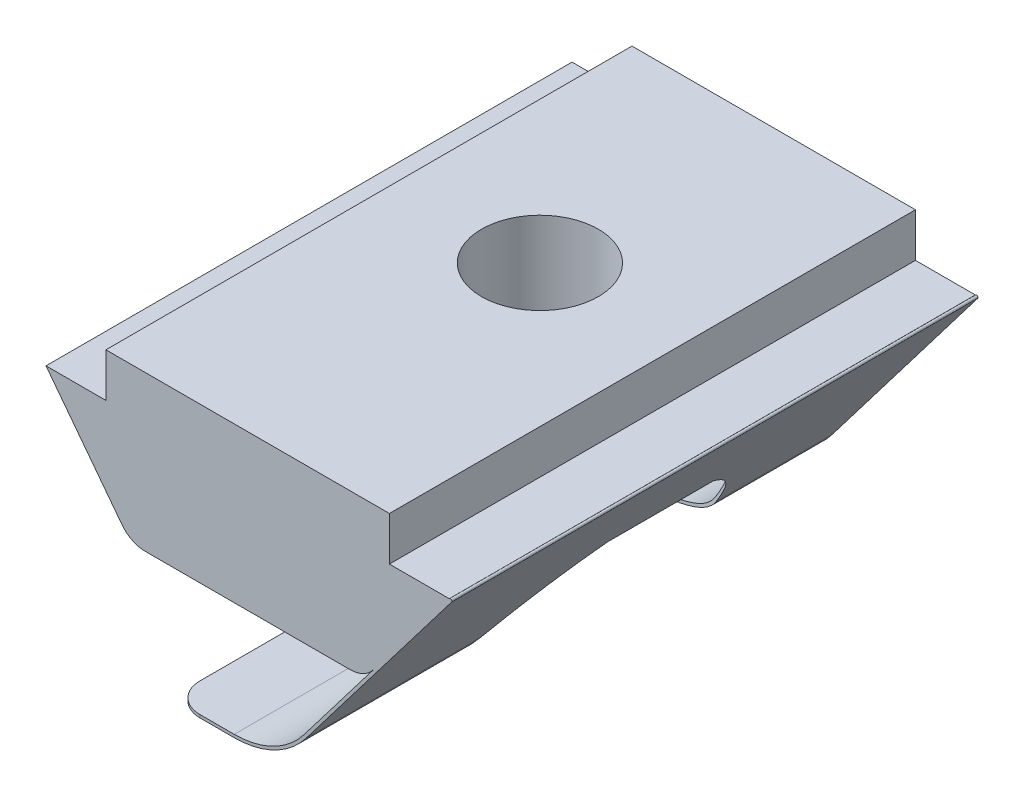
from build123d import *

# Parameters (mm, degrees)
EXTRUDE_1_DEPTH      = 10
EXTRUDE_1_DEPTH_BACK = 8
SKETCH_2_R           = 2
CUT_EXTRUDE_1_DEPTH  = 6.3
EXTRUDE_2_DEPTH      = 18
CUT_EXTRUDE_2_DEPTH  = 4
SKETCH_5_W           = 0.05
SKETCH_5_H           = 18
CUT_EXTRUDE_3_DEPTH  = 1
FILLET_1_R           = 1


with BuildPart() as part:
    # Эскиз1 → Бобышка-Вытянуть1 (new body, two sides)
    with BuildSketch(Plane.XY) as extrude_1_sk:
        with BuildLine():
            Line((3.505219116, 0), (-3.505219116, 0))
            ThreePointArc((-3.505219116, 0), (-3.948686522, 0.1037095), (-4.300170362, 0.393326681))
            Line((-4.300170362, 0.393326681), (-6.9, 3.8))
            Line((-6.9, 3.8), (-4.85, 3.8))
            Line((-4.85, 3.8), (-4.85, 5.3))
            Line((-4.85, 5.3), (4.85, 5.3))
            Line((4.85, 5.3), (4.85, 3.8))
            Line((4.85, 3.8), (6.9, 3.8))
            Line((6.9, 3.8), (4.300170362, 0.393326681))
            ThreePointArc((4.300170362, 0.393326681), (3.948686522, 0.1037095), (3.505219116, 0))
        make_face()
    extrude(amount=EXTRUDE_1_DEPTH)
    extrude(extrude_1_sk.sketch, amount=-EXTRUDE_1_DEPTH_BACK)

    # Эскиз2 → Вырез-Вытянуть1 (cut, through all)
    with BuildSketch(Plane(origin=(0, 5.3, 0), x_dir=(1, 0, 0), z_dir=(0, 1, 0))):
        with Locations(Location((0, 0, 0), (0, 0, 270))):  # turned: the seam where the file's is
            Circle(SKETCH_2_R)
    extrude(amount=-CUT_EXTRUDE_1_DEPTH, mode=Mode.SUBTRACT)

    # Эскиз3 → Бобышка-Вытянуть2 (add)
    with BuildSketch(Plane.XY.offset(10)):
        with BuildLine():
            Line((6.9, 3.8), (1.924195295, -2.720019958))
            ThreePointArc((1.924195295, -2.720019958), (0.869743776, -3.588871499), (-0.460658443, -3.9))
            Line((-0.460658443, -3.9), (-2.630413016, -3.9))
            ThreePointArc((-2.630413016, -3.9), (-2.680413016, -3.95), (-2.630413016, -4))
            Line((-2.630413016, -4), (-0.460658443, -4))
            ThreePointArc((-0.460658443, -4), (0.914090516, -3.678500549), (2.00369042, -2.78068729))
            Line((2.00369042, -2.78068729), (6.979495125, 3.739332668))
            ThreePointArc((6.979495125, 3.739332668), (6.970081228, 3.809413896), (6.9, 3.8))
        make_face()
    extrude(amount=-EXTRUDE_2_DEPTH)

    # Эскиз4 → Вырез-Вытянуть2 (cut)
    with BuildSketch(Plane.XZ.offset(4)):
        with BuildLine():
            Line((0, 4.5), (-4.5, 4.5))
            Line((-4.5, 4.5), (-4.5, 0))
            Line((-4.5, 0), (-4.5, -4.5))
            Line((-4.5, -4.5), (0, -4.5))
            ThreePointArc((0, -4.5), (4.5, 0), (0, 4.5))
        make_face()
    extrude(amount=-CUT_EXTRUDE_2_DEPTH, mode=Mode.SUBTRACT)

    # Эскиз5 → Вырез-Вытянуть3 (cut)
    with BuildSketch(Plane.XZ.offset(4)):
        with Locations((-2.655413016, 1)):
            Rectangle(SKETCH_5_W, SKETCH_5_H)
    extrude(amount=-CUT_EXTRUDE_3_DEPTH, mode=Mode.SUBTRACT)

    # Скругление1
    fillet_1_edges = [part.edges().sort_by_distance(p)[0] for p in [
        (-2.630413016, -3.95, 4.5),
        (-2.630413016, -3.95, -4.5),
        (-2.630413016, -3.95, 10),
        (-2.630413016, -3.95, -8),
    ]]
    fillet(fillet_1_edges, radius=FILLET_1_R)


solid = part.part
